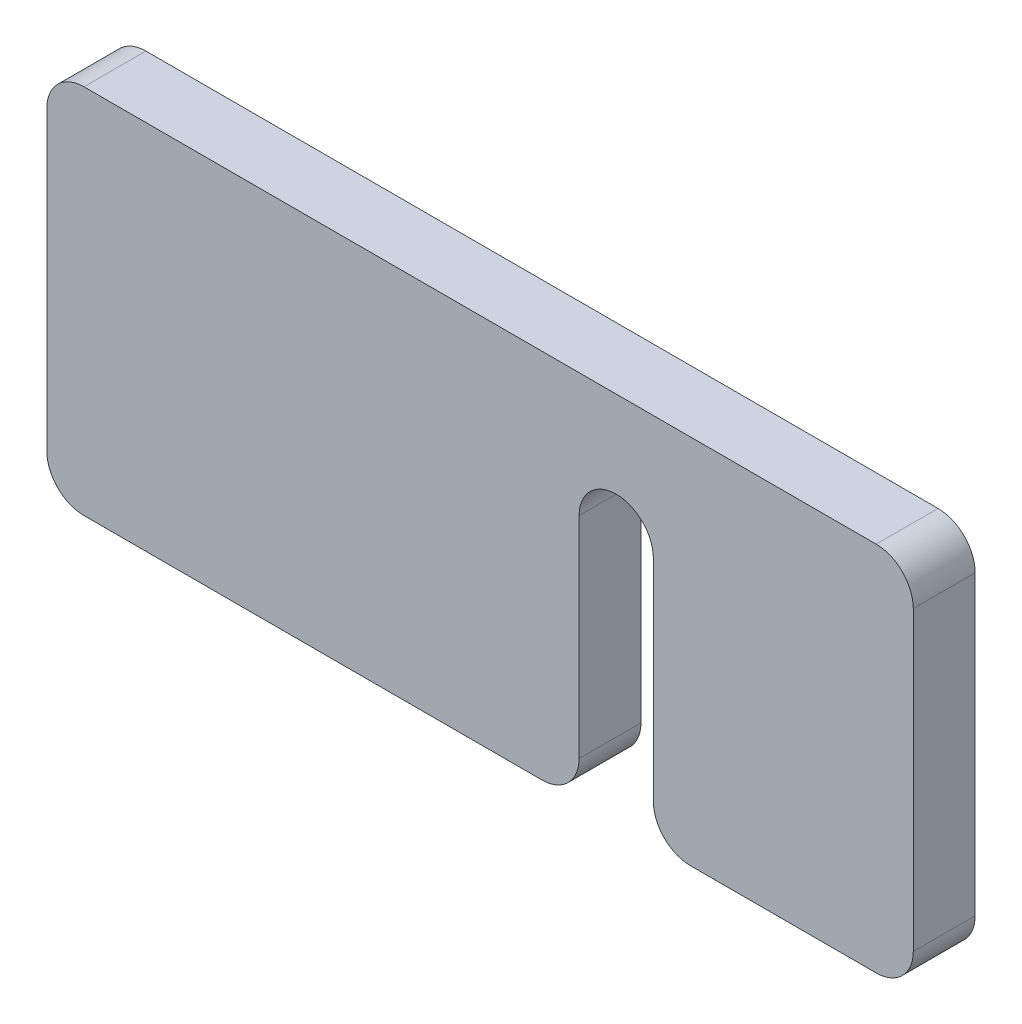
from build123d import *

# Parameters (mm, degrees)
PLAT_W                      = 30
PLAT_H                      = 5
EL_MENT_M_CANO_SOUD_1_DEPTH = 70
ENL_V_MAT_EXTRU_1_DEPTH     = 6
CONG_1_R                    = 3


with BuildPart() as part:
    # plat → Elément mécano-soudé1 (new body)
    with BuildSketch(Plane.YZ.offset(-35)):
        Rectangle(PLAT_W, PLAT_H)
    extrude(amount=EL_MENT_M_CANO_SOUD_1_DEPTH)

    # Esquisse2 → Enlèv. mat.-Extru.1 (cut, through all)
    with BuildSketch(Plane(origin=(0, 0, -2.5), x_dir=(-1, 0, 0), z_dir=(0, 0, -1))):
        with BuildLine():
            Line((-14, -15), (-8, -15))
            Line((-8, -15), (-8, 5))
            ThreePointArc((-8, 5), (-11, 8), (-14, 5))
            Line((-14, 5), (-14, -15))
        make_face()
    extrude(amount=-ENL_V_MAT_EXTRU_1_DEPTH, mode=Mode.SUBTRACT)

    # Congé1
    cong_1_edges = [part.edges().sort_by_distance(p)[0] for p in [
        (35, 15, 0),
        (14, -15, 0),
        (8, -15, 0),
        (35, -15, 0),
        (-35, 15, 0),
        (-35, -15, 0),
    ]]
    fillet(cong_1_edges, radius=CONG_1_R)


solid = part.part
